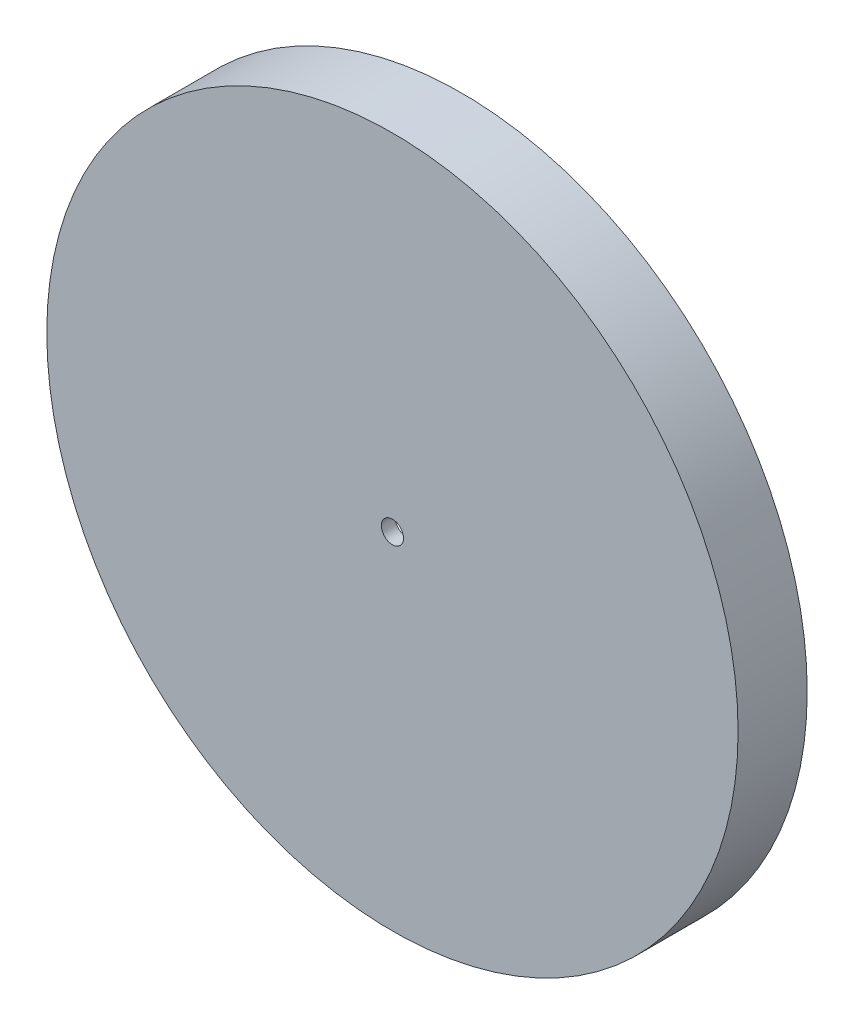
from build123d import *

# Parameters (mm, degrees)
SKETCH1_R           = 62.5
SKETCH1_R_2         = 2
BOSS_EXTRUDE1_DEPTH = 2.5
BOSS_EXTRUDE2_START = -10
SKETCH1_3_R         = 62.5
SKETCH1_3_R_2       = 60
BOSS_EXTRUDE2_DEPTH = 10


with BuildPart() as part:
    # Sketch1 → Boss-Extrude1 (new body)
    with BuildSketch(Plane.XY):
        Circle(SKETCH1_R)
        Circle(SKETCH1_R_2, mode=Mode.SUBTRACT)
    extrude(amount=BOSS_EXTRUDE1_DEPTH)

    # Sketch1_3 → Boss-Extrude2 (add)
    with BuildSketch(Plane.XY.offset(BOSS_EXTRUDE2_START)):
        Circle(SKETCH1_3_R)
        Circle(SKETCH1_3_R_2, mode=Mode.SUBTRACT)
    extrude(amount=BOSS_EXTRUDE2_DEPTH)


solid = part.part
